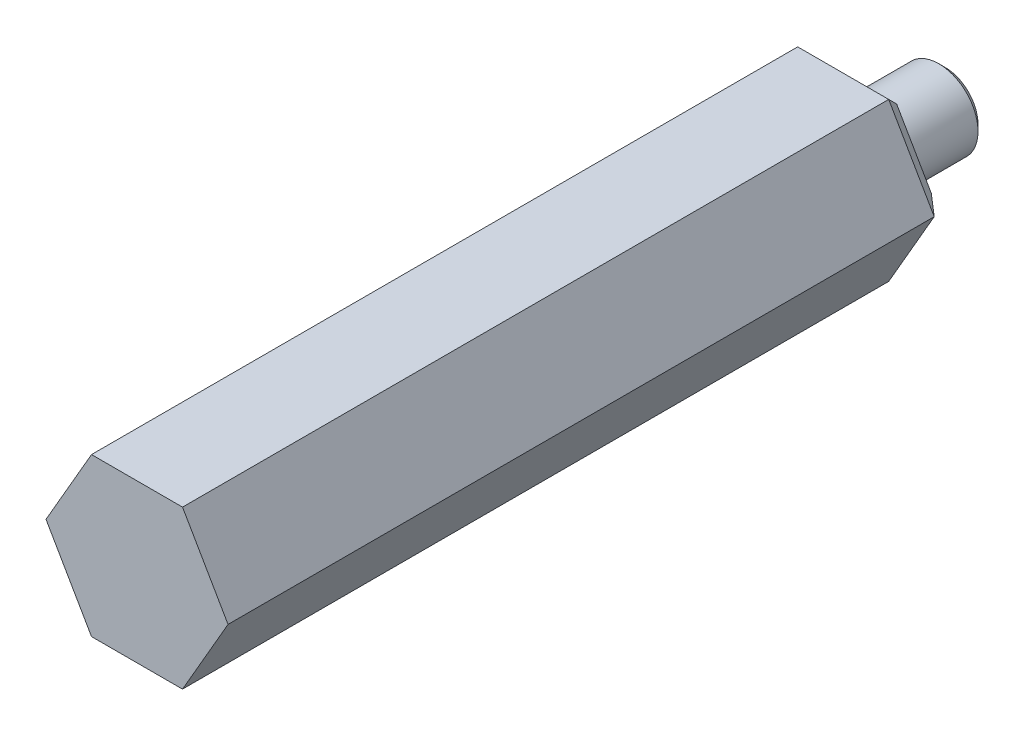
from build123d import *

# Parameters (mm, degrees)
CHAMFER1_SIZE  = 0.50801365
EXTRUDE1_REACH = 60.674
CHAMFER2_SIZE  = 1.524


with BuildPart() as part:
    # Sketch1 → Revolve1 (revolve)
    with BuildSketch(Plane(origin=(0, 0, 0), x_dir=(1, 0, 0), z_dir=(0, 1, 0)), mode=Mode.PRIVATE) as revolve1_sk:
        Polygon((7.366, -29.337), (7.366, 29.337), (3.1623, 29.337), (3.1623, 36.068), (0, 36.068), (0, -29.337), align=None)
    revolve(revolve1_sk.sketch.rotate(Axis((0, 0, -36.068), (0, 0, 1)), 180), axis=Axis((0, 0, -36.068), (0, 0, 1)))  # turned: the seam where the file's is

    # Chamfer1
    chamfer1_edges = [part.edges().sort_by_distance(p)[0] for p in [
        (3.1623, 0, -36.068),
    ]]
    chamfer(chamfer1_edges, length=CHAMFER1_SIZE)

    # Sketch2 → Extrude1 (cut, up to next)
    with BuildSketch(Plane(origin=(0, 0, -29.337), x_dir=(-1, 0, 0), z_dir=(0, 0, -1)), mode=Mode.PRIVATE) as extrude1_sk1:
        with BuildLine():
            ThreePointArc((3.683, 6.379143124), (0, 7.366), (-3.683, 6.379143124))
            Line((-3.683, 6.379143124), (3.683, 6.379143124))
        make_face()
    extrude1_tool1 = extrude(extrude1_sk1.sketch, amount=-EXTRUDE1_REACH, mode=Mode.PRIVATE) & part.part
    add(extrude1_tool1.solids().sort_by_distance((0, 6.776244, -29.337))[0], mode=Mode.SUBTRACT)
    # Sketch2 → Extrude1 (cut, up to next)
    with BuildSketch(Plane(origin=(0, 0, -29.337), x_dir=(-1, 0, 0), z_dir=(0, 0, -1)), mode=Mode.PRIVATE) as extrude1_sk2:
        with BuildLine():
            ThreePointArc((7.366, 0), (6.379143124, 3.683), (3.683, 6.379143124))
            Line((3.683, 6.379143124), (7.366, 0))
        make_face()
    extrude1_tool2 = extrude(extrude1_sk2.sketch, amount=-EXTRUDE1_REACH, mode=Mode.PRIVATE) & part.part
    add(extrude1_tool2.solids().sort_by_distance((-5.868399, 3.388122, -29.337))[0], mode=Mode.SUBTRACT)
    # Sketch2 → Extrude1 (cut, up to next)
    with BuildSketch(Plane(origin=(0, 0, -29.337), x_dir=(-1, 0, 0), z_dir=(0, 0, -1)), mode=Mode.PRIVATE) as extrude1_sk3:
        with BuildLine():
            Line((7.366, 0), (3.683, -6.379143124))
            ThreePointArc((3.683, -6.379143124), (6.379143124, -3.683), (7.366, 0))
        make_face()
    extrude1_tool3 = extrude(extrude1_sk3.sketch, amount=-EXTRUDE1_REACH, mode=Mode.PRIVATE) & part.part
    add(extrude1_tool3.solids().sort_by_distance((-5.868399, -3.388122, -29.337))[0], mode=Mode.SUBTRACT)
    # Sketch2 → Extrude1 (cut, up to next)
    with BuildSketch(Plane(origin=(0, 0, -29.337), x_dir=(-1, 0, 0), z_dir=(0, 0, -1)), mode=Mode.PRIVATE) as extrude1_sk4:
        with BuildLine():
            Line((3.683, -6.379143124), (-3.683, -6.379143124))
            ThreePointArc((-3.683, -6.379143124), (0, -7.366), (3.683, -6.379143124))
        make_face()
    extrude1_tool4 = extrude(extrude1_sk4.sketch, amount=-EXTRUDE1_REACH, mode=Mode.PRIVATE) & part.part
    add(extrude1_tool4.solids().sort_by_distance((0, -6.776244, -29.337))[0], mode=Mode.SUBTRACT)
    # Sketch2 → Extrude1 (cut, up to next)
    with BuildSketch(Plane(origin=(0, 0, -29.337), x_dir=(-1, 0, 0), z_dir=(0, 0, -1)), mode=Mode.PRIVATE) as extrude1_sk5:
        with BuildLine():
            Line((-3.683, -6.379143124), (-7.366, 0))
            ThreePointArc((-7.366, 0), (-6.379143124, -3.683), (-3.683, -6.379143124))
        make_face()
    extrude1_tool5 = extrude(extrude1_sk5.sketch, amount=-EXTRUDE1_REACH, mode=Mode.PRIVATE) & part.part
    add(extrude1_tool5.solids().sort_by_distance((5.868399, -3.388122, -29.337))[0], mode=Mode.SUBTRACT)
    # Sketch2 → Extrude1 (cut, up to next)
    with BuildSketch(Plane(origin=(0, 0, -29.337), x_dir=(-1, 0, 0), z_dir=(0, 0, -1)), mode=Mode.PRIVATE) as extrude1_sk6:
        with BuildLine():
            ThreePointArc((-3.683, 6.379143124), (-6.379143124, 3.683), (-7.366, 0))
            Line((-7.366, 0), (-3.683, 6.379143124))
        make_face()
    extrude1_tool6 = extrude(extrude1_sk6.sketch, amount=-EXTRUDE1_REACH, mode=Mode.PRIVATE) & part.part
    add(extrude1_tool6.solids().sort_by_distance((5.868399, 3.388122, -29.337))[0], mode=Mode.SUBTRACT)

    # Chamfer2
    chamfer2_edges = [part.edges().sort_by_distance(p)[0] for p in [
        (0, 6.379143124, -29.337),
        (-5.5245, 3.189571562, -29.337),
        (-5.5245, -3.189571562, -29.337),
        (0, -6.379143124, -29.337),
        (5.5245, -3.189571562, -29.337),
        (5.5245, 3.189571562, -29.337),
    ]]
    chamfer(chamfer2_edges, length=CHAMFER2_SIZE)


solid = part.part
